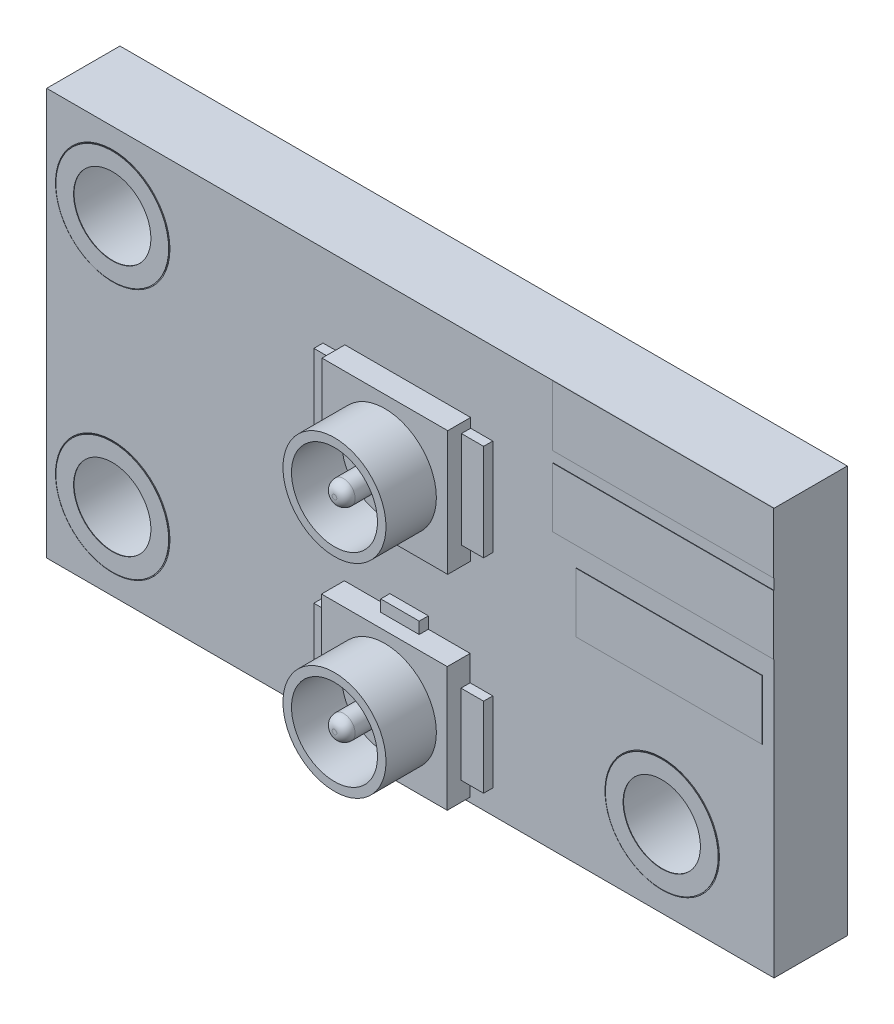
from build123d import *

# Parameters (mm, degrees)
SKETCH_2_W          = 15.883718568
SKETCH_2_H          = 8.883718568
EXTRUDE_1_DEPTH     = 1.6
SKETCH_3_R          = 1.25
CUT_EXTRUDE_1_DEPTH = 2.6
SKETCH_4_W          = 2.745999492
SKETCH_4_H          = 2.718161036
EXTRUDE_2_DEPTH     = 0.5
SKETCH_5_R          = 1.12499557
EXTRUDE_3_DEPTH     = 1.1
SKETCH_6_R          = 0.939144678
SKETCH_6_R_2        = 0.250730718
CUT_EXTRUDE_2_DEPTH = 1.1
SKETCH_7_W          = 4.823876048
SKETCH_7_H          = 1.323618812
SKETCH_7_H_2        = 1.30000254
SKETCH_7_W_2        = 4.064007974
SKETCH_7_H_3        = 1.300002495
EXTRUDE_4_DEPTH     = 0.01
SKETCH_8_R          = 1.23144493
SKETCH_8_R_2        = 0.844305723
EXTRUDE_5_DEPTH     = 0.01
EXTRUDE_5_2_DEPTH   = 0.01
EXTRUDE_5_3_DEPTH   = 0.01
SKETCH_10_W         = 0.477139809
SKETCH_10_H         = 2.109219038
SKETCH_10_W_2       = 0.48327821
SKETCH_10_W_3       = 0.840630776
SKETCH_10_H_2       = 0.260609051
SKETCH_10_W_4       = 0.466430951
SKETCH_10_H_3       = 1.741760788
SKETCH_10_W_5       = 0.493987068
SKETCH_10_H_4       = 0.254356202
EXTRUDE_6_DEPTH     = 0.2
FILLET_1_R          = 0.2


with BuildPart() as part:
    # 草图2 → 凸台-拉伸1 (new body)
    with BuildSketch(Plane.XY):
        with Locations((9.836042672, 5.762001524)):
            Rectangle(SKETCH_2_W, SKETCH_2_H)
    extrude(amount=EXTRUDE_1_DEPTH)

    # 草图3 → 切除-拉伸1 (cut, through all)
    with BuildSketch(Plane.XY.offset(1.6)):
        with Locations((3.336042672, 8.512001524)):
            Circle(SKETCH_3_R)
        with Locations((15.336042672, 3.012001525)):
            Circle(SKETCH_3_R)
        with Locations((3.336042672, 3.012001524)):
            Circle(SKETCH_3_R)
    extrude(amount=-CUT_EXTRUDE_1_DEPTH, mode=Mode.SUBTRACT)

    # 草图4 → 凸台-拉伸2 (add)
    with BuildSketch(Plane.XY.offset(1.6)):
        with Locations((9.7683107, 2.781701931)):
            Rectangle(SKETCH_4_W, SKETCH_4_H)
        with Locations((9.779019558, 7.249047498)):
            Rectangle(SKETCH_4_W, SKETCH_4_H)
    extrude(amount=EXTRUDE_2_DEPTH)

    # 草图5 → 凸台-拉伸3 (add)
    with BuildSketch(Plane.XY.offset(2.1)):
        with Locations((9.779019558, 7.215035087)):
            Circle(SKETCH_5_R)
        with Locations((9.779019558, 2.773456295)):
            Circle(SKETCH_5_R)
    extrude(amount=EXTRUDE_3_DEPTH)

    # 草图6 → 切除-拉伸2 (cut)
    with BuildSketch(Plane.XY.offset(3.2)):
        with Locations((9.779019558, 7.215035087)):
            Circle(SKETCH_6_R)
        with Locations((9.779019558, 7.215035087)):
            Circle(SKETCH_6_R_2, mode=Mode.SUBTRACT)
        with Locations((9.779019558, 2.773456295)):
            Circle(SKETCH_6_R)
        with Locations((9.779019558, 2.773456295)):
            Circle(SKETCH_6_R_2, mode=Mode.SUBTRACT)
    extrude(amount=-CUT_EXTRUDE_2_DEPTH, mode=Mode.SUBTRACT)

    # 草图7 → 凸台-拉伸4 (add)
    with BuildSketch(Plane.XY.offset(1.6)):
        with Locations((15.365963932, 9.549287181)):
            Rectangle(SKETCH_7_W, SKETCH_7_H)
        with Locations((15.365963932, 8.001017272)):
            Rectangle(SKETCH_7_W, SKETCH_7_H_2)
        with Locations((15.494031065, 6.267661948)):
            Rectangle(SKETCH_7_W_2, SKETCH_7_H_3)
    extrude(amount=EXTRUDE_4_DEPTH)

    # 草图10 → 凸台-拉伸6 (add)
    with BuildSketch(Plane.XY.offset(1.6)):
        with Locations((8.167449907, 7.34882997)):
            Rectangle(SKETCH_10_W, SKETCH_10_H)
        with Locations((11.393658409, 7.34882997)):
            Rectangle(SKETCH_10_W_2, SKETCH_10_H)
        with Locations((9.808836101, 5.759662455)):
            Rectangle(SKETCH_10_W_3, SKETCH_10_H_2)
        with Locations((8.162095479, 2.713251358)):
            Rectangle(SKETCH_10_W_4, SKETCH_10_H_3)
        with Locations((11.38830398, 2.713251358)):
            Rectangle(SKETCH_10_W_5, SKETCH_10_H_3)
        with Locations((9.808836101, 4.26796055)):
            Rectangle(SKETCH_10_W_3, SKETCH_10_H_4)
    extrude(amount=EXTRUDE_6_DEPTH)

    # 圆角1
    fillet_1_edges = [part.edges().sort_by_distance(p)[0] for p in [
        (9.52828884, 7.215035087, 3.2),
        (9.52828884, 2.773456295, 3.2),
    ]]
    fillet(fillet_1_edges, radius=FILLET_1_R)


with BuildPart() as body_2:
    # 草图8 → 凸台-拉伸5 (new body)
    with BuildSketch(Plane.XY.offset(1.6)):
        with Locations((3.336042672, 8.512001524)):
            Circle(SKETCH_8_R)
        with Locations((3.336042672, 8.512001524)):
            Circle(SKETCH_8_R_2, mode=Mode.SUBTRACT)
    extrude(amount=EXTRUDE_5_DEPTH)


with BuildPart() as body_3:
    # 草图8 → Extrude 5 2 (new body)
    with BuildSketch(Plane.XY.offset(1.6)):
        with Locations((3.336042672, 3.012001524)):
            Circle(SKETCH_8_R)
        with Locations((3.336042672, 3.012001524)):
            Circle(SKETCH_8_R_2, mode=Mode.SUBTRACT)
    extrude(amount=EXTRUDE_5_2_DEPTH)


with BuildPart() as body_4:
    # 草图8 → Extrude 5 3 (new body)
    with BuildSketch(Plane.XY.offset(1.6)):
        with Locations((15.336042672, 3.012001525)):
            Circle(SKETCH_8_R)
        with Locations((15.336042672, 3.012001525)):
            Circle(SKETCH_8_R_2, mode=Mode.SUBTRACT)
    extrude(amount=EXTRUDE_5_3_DEPTH)


solid = Compound([part.part, body_2.part, body_3.part, body_4.part])
